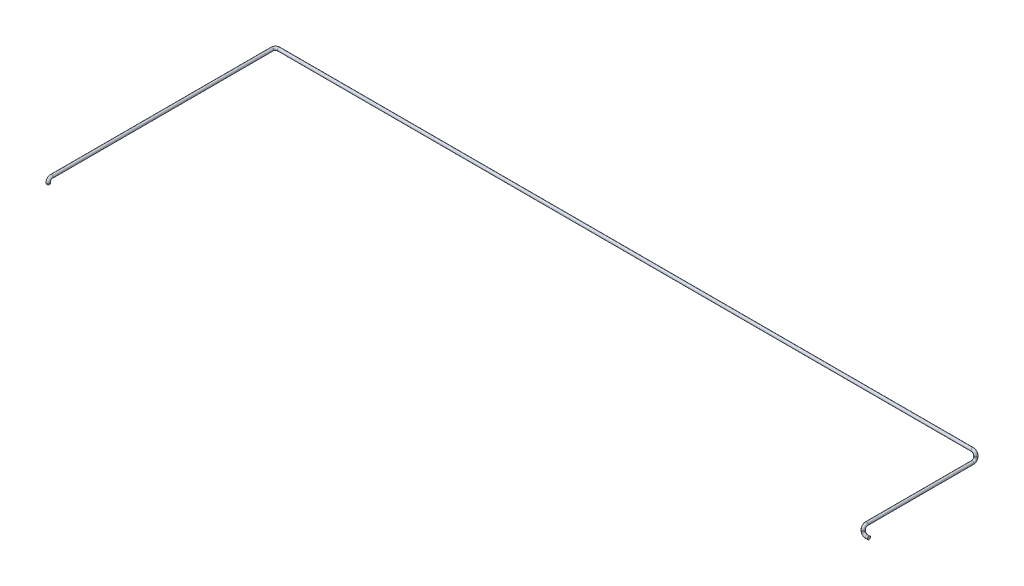
from build123d import *

# Parameters (mm, degrees)
CROQUIS1_R = 13.7


with BuildPart() as part:
    # Barrer1: sweep along a curve in space
    with BuildLine() as barrer1_path:
        Line((0, 0, 0), (-20, 0, 0))
        ThreePointArc((-20, 0, 0), (-41.213203436, 8.786796564, 0), (-50, 30, 0))
        Line((-50, 30, 0), (-50, 40, 0))
        ThreePointArc((-50, 40, 0), (-50, 61.213203436, -8.786796564), (-50, 70, -30))
        Line((-50, 70, -30), (-50, 70, -970))
        ThreePointArc((-50, 100, -1000), (-50, 78.786796564, -991.213203436), (-50, 70, -970))
        Line((-50, 100, -1000), (-50, 110, -1000))
        ThreePointArc((-50, 110, -1000), (-58.786796564, 131.213203436, -1000), (-80, 140, -1000))
        Line((-80, 140, -1000), (-6245, 140, -1000))
        ThreePointArc((-6245, 140, -1000), (-6266.213203436, 140, -991.213203436), (-6275, 140, -970))
        Line((-6275, 140, -970), (-6275, 140, 990))
        ThreePointArc((-6275, 140, 990), (-6275, 131.213203436, 1011.213203436), (-6275, 110, 1020))
        Line((-6275, 110, 1020), (-6275, 100, 1020))
    # Croquis1 → Barrer1 (sweep)
    with BuildSketch(Plane(origin=(0, 0, 0), x_dir=(0, 0, -1), z_dir=(1, 0, 0))):
        Circle(CROQUIS1_R)
    sweep(path=barrer1_path.line)


solid = part.part
